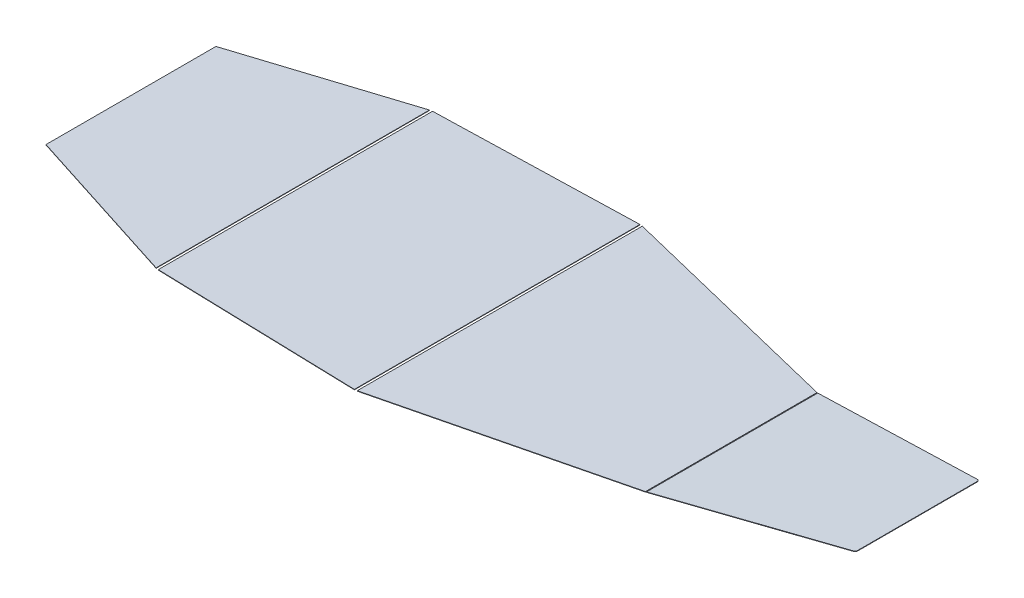
from build123d import *

# Parameters (mm, degrees)
BOSS_EXTRUDE1_DEPTH         = 1
BOSS_EXTRUDE1_2_DEPTH       = 1
BOSS_EXTRUDE1_3_DEPTH       = 1
BOSS_EXTRUDEREARFLOOR_START = -1
BOSS_EXTRUDEREARFLOOR_DEPTH = 1


with BuildPart() as part:
    # Sketch1 → Boss-Extrude1 (new body)
    with BuildSketch(Plane.XZ.offset(-59.3)):
        Polygon((2084.05, 196.849875822), (2084.05, -196.849875822), (1552.679093518, -327.117712255), (1552.679093518, 327.117712255), align=None)
    extrude(amount=-BOSS_EXTRUDE1_DEPTH)


with BuildPart() as body_2:
    # Sketch1 → Boss-Extrude1 2 (new body)
    with BuildSketch(Plane.XZ.offset(-59.3)):
        Polygon((1083.51849794, 314.797366573), (1083.51849794, -314.797366573), (1546.679093518, -327.769153695), (1546.679093518, 327.769153694), align=None)
    extrude(amount=-BOSS_EXTRUDE1_2_DEPTH)


with BuildPart() as body_3:
    # Sketch1 → Boss-Extrude1 3 (new body)
    with BuildSketch(Plane.XZ.offset(-59.3)):
        Polygon((1077.51849794, 313.757852783), (1077.51849794, -313.757852783), (706, -195.067870365), (706, 195.067870365), align=None)
    extrude(amount=-BOSS_EXTRUDE1_3_DEPTH)


with BuildPart() as body_4:
    # Sketch2 → Boss-ExtrudeRearFloor (new body)
    with BuildSketch(Plane(origin=(40.876638844, -260.919378418, 0), x_dir=(0.987949588, 0.154776003, 0), z_dir=(0.154776003, -0.987949588, 0)).offset(BOSS_EXTRUDEREARFLOOR_START)):
        with BuildLine():
            Line((2070.355518515, -196.475045869), (2495.674764696, -142.327861196))
            ThreePointArc((2495.674764696, -142.327861196), (2499.419603214, -140.34160117), (2500.917023581, -136.375901149))
            Line((2500.917023581, -136.375901149), (2500.917023581, -58.444774641))
            Line((2500.917023581, -58.444774641), (2500.917023581, 58.444774641))
            Line((2500.917023581, 58.444774641), (2500.917023581, 136.375901149))
            ThreePointArc((2500.917023581, 136.375901149), (2499.419603214, 140.34160117), (2495.674764696, 142.327861196))
            Line((2495.674764696, 142.327861196), (2070.355518515, 196.475045869))
            Line((2070.355518515, 196.475045869), (2070.355518515, -196.475045869))
        make_face()
    extrude(amount=BOSS_EXTRUDEREARFLOOR_DEPTH)


solid = Compound([part.part, body_2.part, body_3.part, body_4.part])
